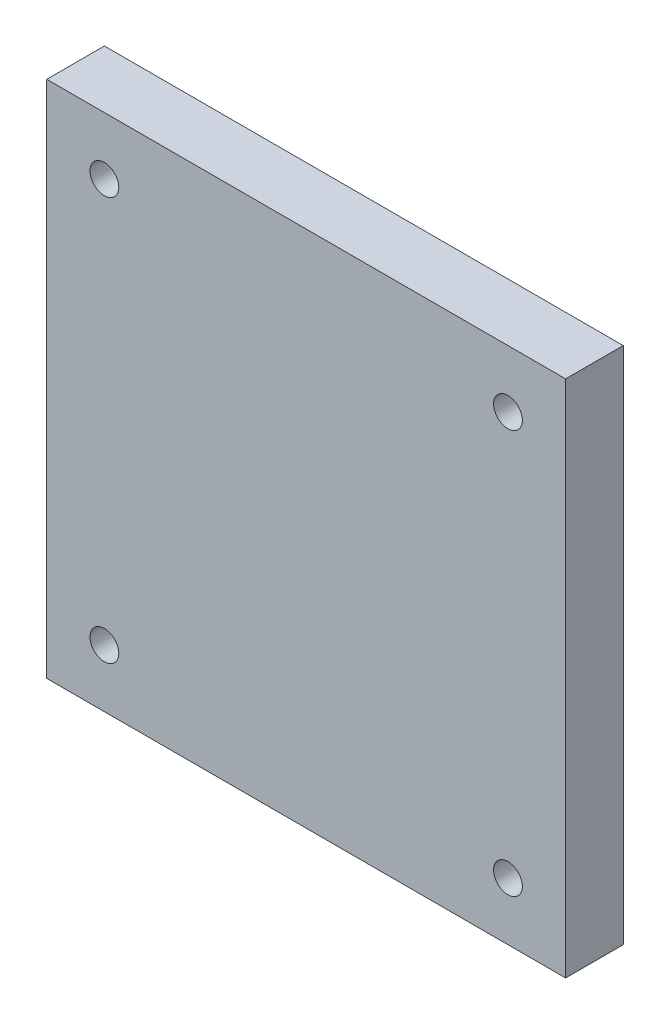
from build123d import *

# Parameters (mm, degrees)
ESQUISSE1_W                                   = 45
ESQUISSE1_H                                   = 45
BOSS_EXTRU_1_DEPTH                            = 5
TROU_POUR_TARAUDAGE_POUR_TROU_TARAUD_M3_D     = 2.5
TROU_POUR_TARAUDAGE_POUR_TROU_TARAUD_M3_DEPTH = 10
TROU_POUR_TARAUDAGE_POUR_TROU_TARAUD_M3_TIP   = 0.751075774


with BuildPart() as part:
    # Esquisse1 → Boss.-Extru.1 (new body)
    with BuildSketch(Plane.XY):
        with Locations((22.5, 22.5)):
            Rectangle(ESQUISSE1_W, ESQUISSE1_H)
    extrude(amount=BOSS_EXTRU_1_DEPTH)

    # Trou pour taraudage pour trou taraudé M3x0.51
    with Locations(Plane.XY.offset(5)):
        with Locations((5, 40), (40, 5), (40, 40), (5, 5)):
            Hole(TROU_POUR_TARAUDAGE_POUR_TROU_TARAUD_M3_D / 2, depth=TROU_POUR_TARAUDAGE_POUR_TROU_TARAUD_M3_DEPTH)
            with Locations((0, 0, -(TROU_POUR_TARAUDAGE_POUR_TROU_TARAUD_M3_DEPTH + TROU_POUR_TARAUDAGE_POUR_TROU_TARAUD_M3_TIP / 2))):  # 118° drill point
                Cone(0, TROU_POUR_TARAUDAGE_POUR_TROU_TARAUD_M3_D / 2, TROU_POUR_TARAUDAGE_POUR_TROU_TARAUD_M3_TIP, mode=Mode.SUBTRACT)


solid = part.part
